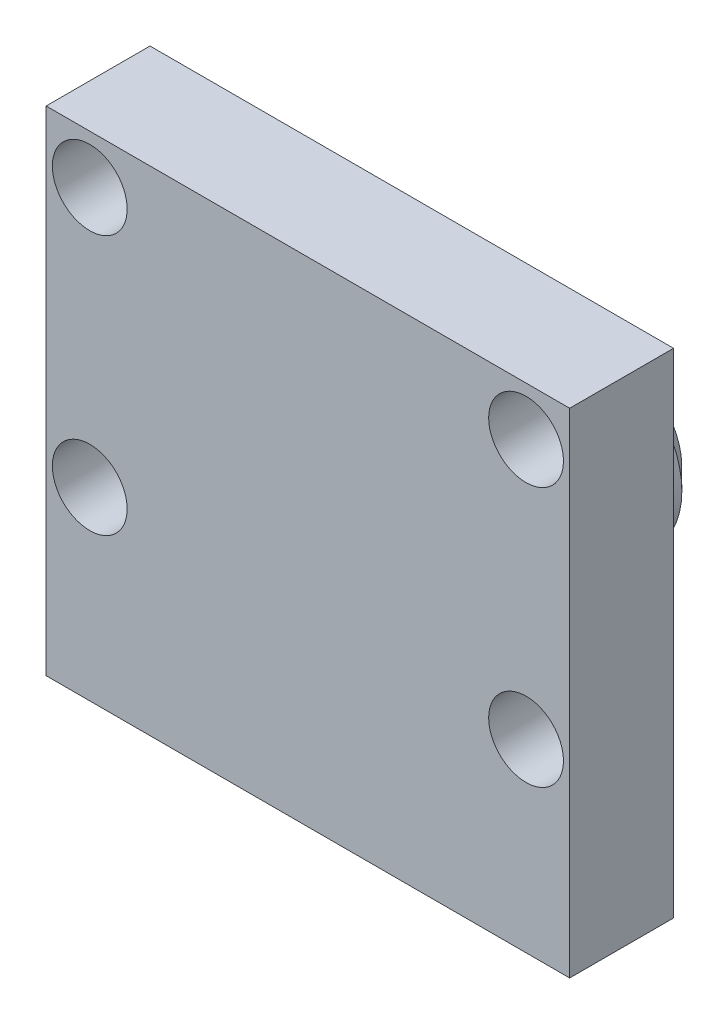
from build123d import *

# Parameters (mm, degrees)
SKETCH2_W           = 25.2
SKETCH2_H           = 23.75
BOSS_EXTRUDE1_DEPTH = 5
SKETCH3_R           = 1.8
CUT_EXTRUDE1_DEPTH  = 6
SKETCH4_W           = 11.2
SKETCH4_H           = 11.2
BOSS_EXTRUDE2_DEPTH = 6
SKETCH5_R           = 4
BOSS_EXTRUDE3_DEPTH = 4
SKETCH6_R           = 2.5
CUT_EXTRUDE2_DEPTH  = 1
SKETCH6_2_R         = 2.5
BOSS_EXTRUDE4_DEPTH = 1
CHAMFER1_SIZE       = 1


with BuildPart() as part:
    # Sketch2 → Boss-Extrude1 (new body)
    with BuildSketch(Plane.XY):
        with Locations((0, 41.875)):
            Rectangle(SKETCH2_W, SKETCH2_H)
    extrude(amount=BOSS_EXTRUDE1_DEPTH)

    # Sketch3 → Cut-Extrude1 (cut, through all)
    with BuildSketch(Plane(origin=(0, 0, 0), x_dir=(-1, 0, 0), z_dir=(0, 0, -1))):
        with Locations((-10.5, 51.4)):
            Circle(SKETCH3_R)
        with Locations((10.5, 51.4)):
            Circle(SKETCH3_R)
        with Locations((10.5, 38.9)):
            Circle(SKETCH3_R)
        with Locations((-10.5, 38.9)):
            Circle(SKETCH3_R)
    extrude(amount=-CUT_EXTRUDE1_DEPTH, mode=Mode.SUBTRACT)

    # Sketch4 → Boss-Extrude2 (add)
    with BuildSketch(Plane(origin=(0, 0, 0), x_dir=(-1, 0, 0), z_dir=(0, 0, -1))):
        with Locations((0, 39)):
            Rectangle(SKETCH4_W, SKETCH4_H)
    extrude(amount=BOSS_EXTRUDE2_DEPTH)

    # Sketch5 → Boss-Extrude3 (add)
    with BuildSketch(Plane(origin=(0, 0, -6), x_dir=(-1, 0, 0), z_dir=(0, 0, -1))):
        with Locations((0, 39)):
            Circle(SKETCH5_R)
    extrude(amount=BOSS_EXTRUDE3_DEPTH)

    # Sketch6 → Cut-Extrude2 (cut)
    with BuildSketch(Plane(origin=(0, 0, -10), x_dir=(-1, 0, 0), z_dir=(0, 0, -1))):
        with Locations((0, 39)):
            Circle(SKETCH6_R)
    extrude(amount=-CUT_EXTRUDE2_DEPTH, mode=Mode.SUBTRACT)

    # Chamfer1
    chamfer1_edges = [part.edges().sort_by_distance(p)[0] for p in [
        (-5.6, 39, -6),
        (0, 44.6, -6),
        (5.6, 39, -6),
        (0, 33.4, -6),
        (4, 39, -10),
    ]]
    chamfer(chamfer1_edges, length=CHAMFER1_SIZE)


with BuildPart() as body_2:
    # Sketch6_2 → Boss-Extrude4 (new body)
    with BuildSketch(Plane(origin=(0, 0, -10), x_dir=(-1, 0, 0), z_dir=(0, 0, -1))):
        with Locations((0, 39)):
            Circle(SKETCH6_2_R)
    extrude(amount=-BOSS_EXTRUDE4_DEPTH)


solid = Compound([part.part, body_2.part])
